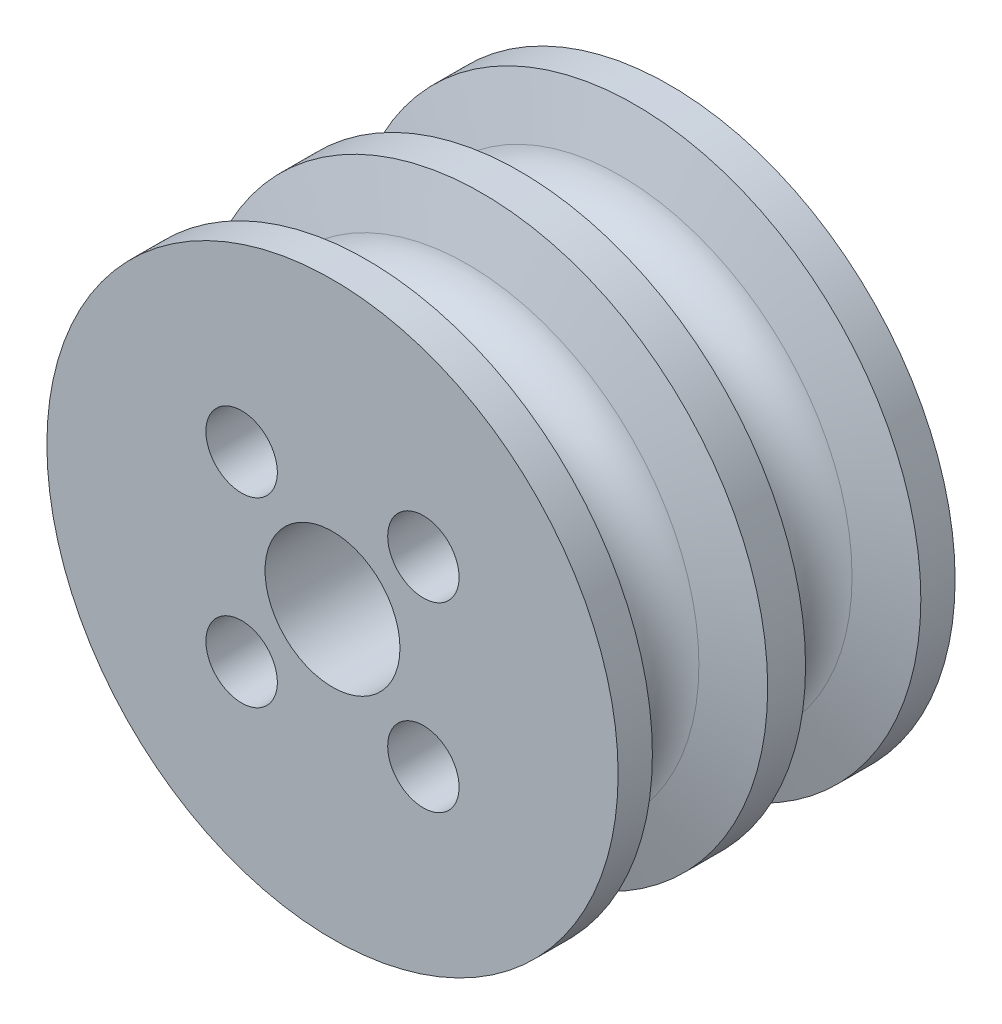
from build123d import *

# Parameters (mm, degrees)
SKETCH2_R          = 1.5875
CUT_EXTRUDE1_DEPTH = 14.984431


with BuildPart() as part:
    # Sketch1 → Revolve1 (revolve)
    with BuildSketch(Plane(origin=(0, 0, 0), x_dir=(0, 0, -1), z_dir=(1, 0, 0))):
        with BuildLine():
            Line((-1.488284524, 10.287553907), (-0.841871541, 12.7))
            Line((-0.841871541, 12.7), (0.841871541, 12.7))
            Line((0.841871541, 12.7), (1.488284524, 10.287553907))
            ThreePointArc((1.488284524, 10.287553907), (3.405043585, 8.81677295), (5.321802647, 10.287553907))
            Line((5.321802647, 10.287553907), (5.968215629, 12.7))
            Line((5.968215629, 12.7), (7.492215629, 12.7))
            Line((7.492215629, 12.7), (7.492215629, 4.127000001))
            Line((7.492215629, 4.127000001), (4.492215629, 4.127000001))
            Line((4.492215629, 4.127000001), (4.492215629, 3))
            Line((4.492215629, 3), (-7.492215629, 3))
            Line((-7.492215629, 3), (-7.492215629, 12.7))
            Line((-7.492215629, 12.7), (-5.968215629, 12.7))
            Line((-5.968215629, 12.7), (-5.321802647, 10.287553907))
            ThreePointArc((-5.321802647, 10.287553907), (-3.405043585, 8.81677295), (-1.488284524, 10.287553907))
        make_face()
    revolve(axis=Axis((0, 0, 0), (0, 0, -1)))

    # Sketch2 → Cut-Extrude1 (cut)
    with BuildSketch(Plane(origin=(0, 0, -7.492215629), x_dir=(-1, 0, 0), z_dir=(0, 0, -1))):
        with Locations((4.041115254, 4.041115254)):
            Circle(SKETCH2_R)
        with Locations((-4.041115254, 4.041115254)):
            Circle(SKETCH2_R)
        with Locations((-4.041115254, -4.041115254)):
            Circle(SKETCH2_R)
        with Locations((4.041115254, -4.041115254)):
            Circle(SKETCH2_R)
    extrude(amount=-CUT_EXTRUDE1_DEPTH, mode=Mode.SUBTRACT)


solid = part.part
